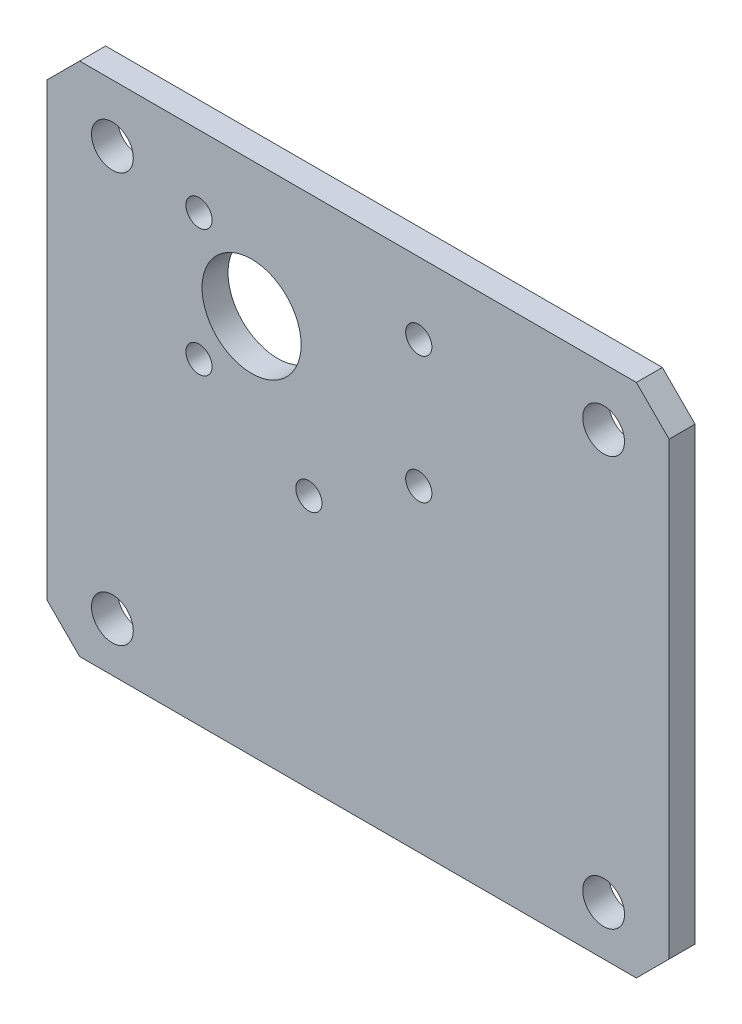
from build123d import *

# Parameters (mm, degrees)
SKETCH1_W               = 76
SKETCH1_H               = 63
SKETCH1_R               = 6.05
SKETCH1_R_2             = 1.6
BOSS_EXTRUDE1_DEPTH     = 3.175
CHAMFER1_SIZE           = 4
F_1_4_20_TAPPED_HOLE1_D = 5.1054


with BuildPart() as part:
    # Sketch1 → Boss-Extrude1 (new body)
    with BuildSketch(Plane.XY):
        with Locations((6, -14.99999999)):
            Rectangle(SKETCH1_W, SKETCH1_H)
        with Locations((-7, 0)):
            Circle(SKETCH1_R, mode=Mode.SUBTRACT)
        with Locations((-13.423393759, 7.75)):
            Circle(SKETCH1_R_2, mode=Mode.SUBTRACT)
        with Locations((-13.423393759, -7.75)):
            Circle(SKETCH1_R_2, mode=Mode.SUBTRACT)
        with Locations((0, -15.5)):
            Circle(SKETCH1_R_2, mode=Mode.SUBTRACT)
        with Locations((13.423393759, -7.75)):
            Circle(SKETCH1_R_2, mode=Mode.SUBTRACT)
        with Locations((13.423393759, 7.75)):
            Circle(SKETCH1_R_2, mode=Mode.SUBTRACT)
    extrude(amount=BOSS_EXTRUDE1_DEPTH)

    # Chamfer1
    chamfer1_edges = [part.edges().sort_by_distance(p)[0] for p in [
        (44, -46.49999999, 1.5875),
        (44, 16.50000001, 1.5875),
        (-32, -46.49999999, 1.5875),
        (-32, 16.50000001, 1.5875),
    ]]
    chamfer(chamfer1_edges, length=CHAMFER1_SIZE)

    # 1_4-20 Tapped Hole1 (through all)
    with Locations(Plane.XY.offset(3.175)):
        with Locations((-24, 9.50000001), (36, 9.50000001), (36, -40.49999999), (-24, -40.49999999)):
            Hole(F_1_4_20_TAPPED_HOLE1_D / 2)


solid = part.part
